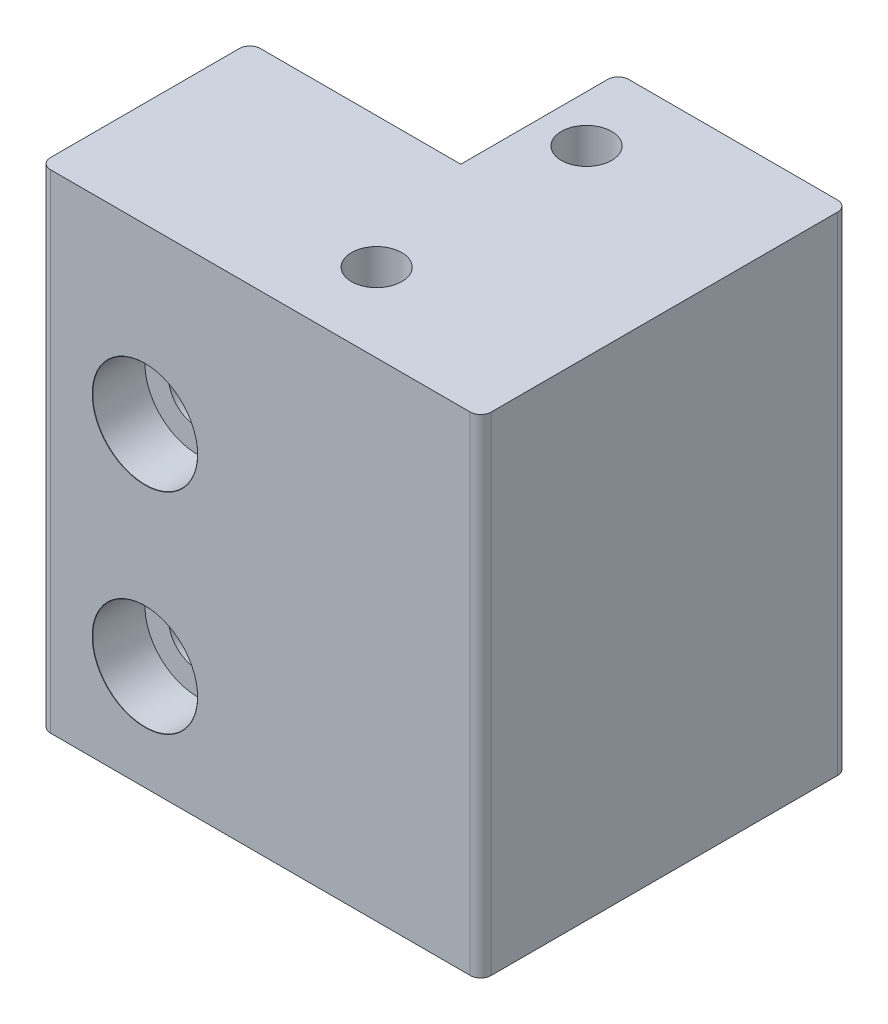
from build123d import *

# Parameters (mm, degrees)
SKETCH1_W                     = 42
SKETCH1_H                     = 20
BOSS_EXTRUDE1_DEPTH           = 40
SKETCH2_W                     = 21.9
SKETCH2_H                     = 15
BOSS_EXTRUDE2_DEPTH           = 40
CBORE_FOR_M5_SHCS1_AT_2_COUNT = 2
CBORE_FOR_M5_SHCS1_AT_2_PITCH = 20
BOSS_EXTRUDE3_DEPTH           = 6.5
FILLET1_R                     = 1
SKETCH8_R                     = 2.4
CUT_EXTRUDE1_DEPTH            = 3.8
SKETCH9_R                     = 1.65
CUT_EXTRUDE2_DEPTH            = 3


with BuildPart() as part:
    # Sketch1 → Boss-Extrude1 (new body)
    with BuildSketch(Plane(origin=(0, 0, 0), x_dir=(1, 0, 0), z_dir=(0, 1, 0))):
        Rectangle(SKETCH1_W, SKETCH1_H)
    extrude(amount=BOSS_EXTRUDE1_DEPTH)

    # Sketch2 → Boss-Extrude2 (add)
    with BuildSketch(Plane(origin=(0, 40, 0), x_dir=(1, 0, 0), z_dir=(0, 1, 0))):
        with Locations((10.05, 17.5)):
            Rectangle(SKETCH2_W, SKETCH2_H)
    extrude(amount=-BOSS_EXTRUDE2_DEPTH)

    # Sketch5 → CBORE for M5 SHCS1 (revolve, cut)
    with BuildSketch(Plane(origin=(-11, 30, 10), x_dir=(0, -1, 0), z_dir=(1, 0, 0))):
        Polygon((0, 0), (0, 35), (2.75, 35), (2.75, 5), (5, 5), (5, 0.020977491), (5.025, 0), align=None)
    cbore_for_m5_shcs1 = revolve(axis=Axis((-11, 30, 16.35), (0, 0, -1)), mode=Mode.SUBTRACT)

    # CBORE for M5 SHCS1 at 2: CBORE for M5 SHCS1 ×2
    with Locations(*[(0, -i * CBORE_FOR_M5_SHCS1_AT_2_PITCH, 0) for i in range(1, CBORE_FOR_M5_SHCS1_AT_2_COUNT)]):
        add(cbore_for_m5_shcs1, mode=Mode.SUBTRACT)

    # Sketch6 → Boss-Extrude3 (add)
    with BuildSketch(Plane(origin=(0, 40, 0), x_dir=(1, 0, 0), z_dir=(0, 1, 0))):
        Polygon((-21, 10), (-21, -10), (21, -10), (21, 25), (-0.9, 25), (-0.9, 10), align=None)
    extrude(amount=BOSS_EXTRUDE3_DEPTH)

    # Fillet1
    fillet1_edges = [part.edges().sort_by_distance(p)[0] for p in [
        (-0.9, 23.25, -25),
        (21, 23.25, -25),
        (-21, 23.25, -10),
        (21, 23.25, 10),
        (-21, 23.25, 10),
    ]]
    fillet(fillet1_edges, radius=FILLET1_R)

    # Sketch8 → Cut-Extrude1 (cut)
    with BuildSketch(Plane(origin=(0, 46.5, 0), x_dir=(1, 0, 0), z_dir=(0, 1, 0))):
        with Locations((3.58, 17.5)):
            Circle(SKETCH8_R)
        with Locations((3.58, -2.5)):
            Circle(SKETCH8_R)
    extrude(amount=-CUT_EXTRUDE1_DEPTH, mode=Mode.SUBTRACT)

    # Sketch9 → Cut-Extrude2 (cut)
    with BuildSketch(Plane(origin=(0, 42.7, 0), x_dir=(1, 0, 0), z_dir=(0, 1, 0))):
        with Locations((3.58, 17.5)):
            Circle(SKETCH9_R)
        with Locations((3.58, -2.5)):
            Circle(SKETCH9_R)
    extrude(amount=-CUT_EXTRUDE2_DEPTH, mode=Mode.SUBTRACT)


solid = part.part
